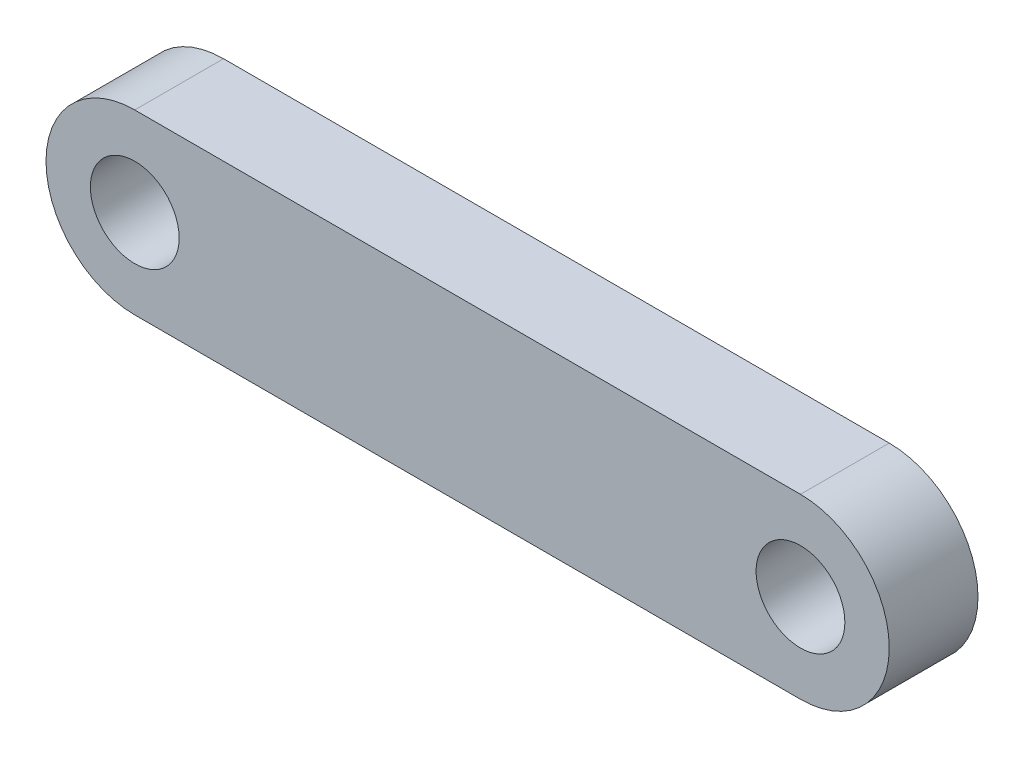
from build123d import *

# Parameters (mm, degrees)
SKETCH1_R           = 5
BOSS_EXTRUDE1_DEPTH = 10


with BuildPart() as part:
    # Sketch1 → Boss-Extrude1 (new body)
    with BuildSketch(Plane.XY):
        with BuildLine():
            Line((-37.5, 10), (37.5, 10))
            ThreePointArc((37.5, 10), (47.5, 0), (37.5, -10))
            Line((37.5, -10), (-37.5, -10))
            ThreePointArc((-37.5, -10), (-47.5, 0), (-37.5, 10))
        make_face()
        with Locations((-37.5, 0)):
            Circle(SKETCH1_R, mode=Mode.SUBTRACT)
        with Locations((37.5, 0)):
            Circle(SKETCH1_R, mode=Mode.SUBTRACT)
    extrude(amount=-BOSS_EXTRUDE1_DEPTH)


solid = part.part
